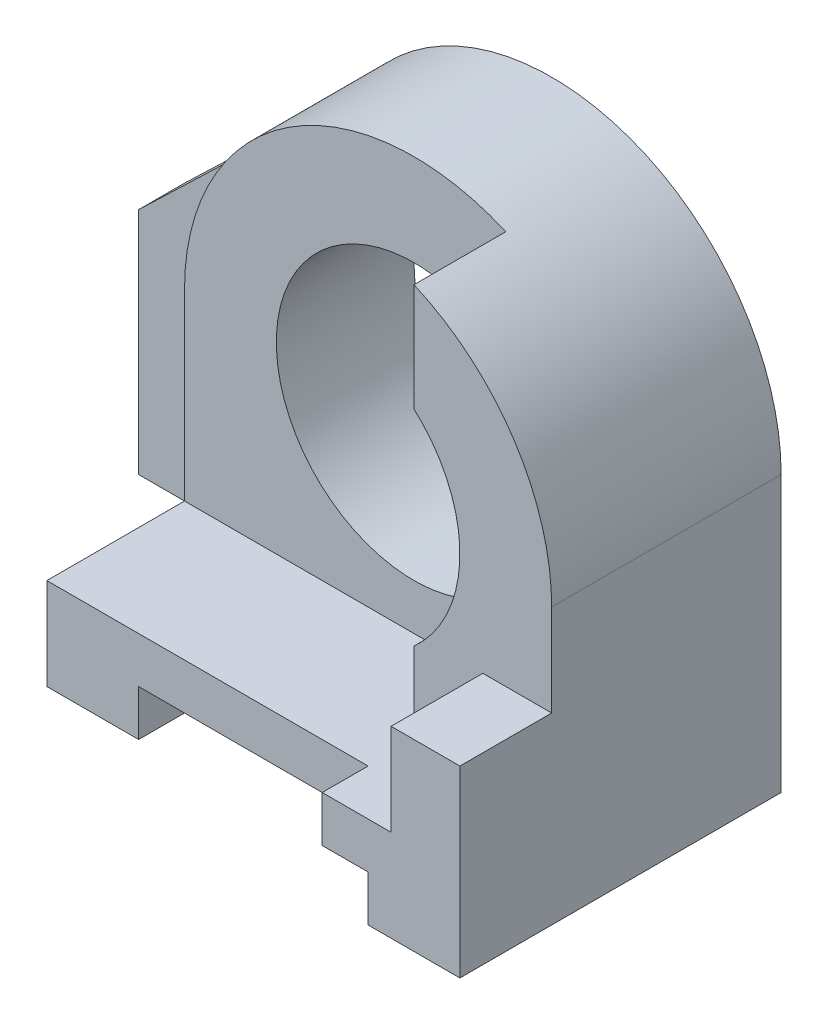
from build123d import *

# Parameters (mm, degrees)
SKETCH1_R           = 3
BOSS_EXTRUDE1_DEPTH = 7
BOSS_EXTRUDE2_DEPTH = 1
CUT_EXTRUDE1_DEPTH  = 2
CUT_EXTRUDE2_DEPTH  = 12
CUT_EXTRUDE3_DEPTH  = 12


with BuildPart() as part:
    # Sketch1 → Boss-Extrude1 (new body)
    with BuildSketch(Plane.XY):
        with BuildLine():
            Line((0, 0), (2, 0))
            Line((2, 0), (2, 1))
            Line((2, 1), (8, 1))
            Line((8, 1), (8, 0))
            Line((8, 0), (10, 0))
            Line((10, 0), (10, 6))
            ThreePointArc((10, 6), (5, 11), (0, 6))
            Line((0, 6), (0, 0))
        make_face()
        with Locations((5, 6)):
            Circle(SKETCH1_R, mode=Mode.SUBTRACT)
    extrude(amount=BOSS_EXTRUDE1_DEPTH)

    # Sketch2 → Boss-Extrude2 (add)
    with BuildSketch(Plane(origin=(0, 0, 0), x_dir=(-1, 0, 0), z_dir=(0, 0, -1))):
        Polygon((0, 0), (3, 0), (3, 5), (-0.705752773, 8.561140517), (-0.311985877, 0), align=None)
    extrude(amount=-BOSS_EXTRUDE2_DEPTH)

    # Sketch3 → Cut-Extrude1 (cut)
    with BuildSketch(Plane.XY.offset(7)):
        Polygon((7, 10.582575695), (7, 2), (8.5, 2), (8.5, 4), (10, 4), (10, 10.582575695), align=None)
    extrude(amount=-CUT_EXTRUDE1_DEPTH, mode=Mode.SUBTRACT)

    # Sketch4 → Cut-Extrude2 (cut)
    with BuildSketch(Plane(origin=(0, 0, 0), x_dir=(1, 0, 0), z_dir=(0, 1, 0))):
        Polygon((7, -7), (7, -6), (0, -6), (-0.727181491, -7.463826734), (7.362536443, -7.463826734), align=None)
    extrude(amount=CUT_EXTRUDE2_DEPTH, mode=Mode.SUBTRACT)

    # Sketch5 → Cut-Extrude3 (cut)
    with BuildSketch(Plane(origin=(0, 2, 0), x_dir=(1, 0, 0), z_dir=(0, 1, 0))):
        Polygon((7, -5), (7, -3), (0, -3), (0, -6), (7, -6), align=None)
    extrude(amount=CUT_EXTRUDE3_DEPTH, mode=Mode.SUBTRACT)


solid = part.part
